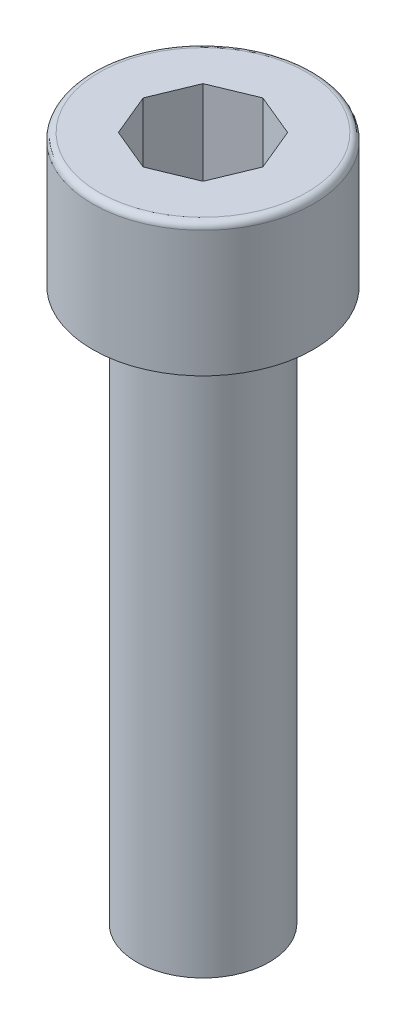
from build123d import *

# Parameters (mm, degrees)
SKETCH1_R           = 3
BOSS_EXTRUDE1_DEPTH = 25
SKETCH2_R           = 5
SKETCH2_R_2         = 3
BOSS_EXTRUDE2_DEPTH = 6
FILLET1_R           = 0.3
FILLET2_R           = 0.25


with BuildPart() as part:
    # Sketch1 → Boss-Extrude1 (new body)
    with BuildSketch(Plane(origin=(0, 0, 0), x_dir=(1, 0, 0), z_dir=(0, 1, 0))):
        Circle(SKETCH1_R)
    extrude(amount=BOSS_EXTRUDE1_DEPTH)

    # Sketch2 → Boss-Extrude2 (add)
    with BuildSketch(Plane(origin=(0, 25, 0), x_dir=(1, 0, 0), z_dir=(0, 1, 0))):
        Circle(SKETCH2_R)
        Circle(SKETCH2_R_2, mode=Mode.SUBTRACT)
        Circle(SKETCH2_R_2)
        Polygon((1.913417162, -1.913417162), (2.705980501, 0), (1.913417162, 1.913417162), (0, 2.705980501), (-1.913417162, 1.913417162), (-2.705980501, 0), (-1.913417162, -1.913417162), (0, -2.705980501), align=None, mode=Mode.SUBTRACT)
    extrude(amount=BOSS_EXTRUDE2_DEPTH)

    # Fillet1
    fillet1_edges = [part.edges().sort_by_distance(p)[0] for p in [
        (-5, 31, 0),
    ]]
    fillet(fillet1_edges, radius=FILLET1_R)

    # Fillet2
    fillet2_edges = [part.edges().sort_by_distance(p)[0] for p in [
        (-3, 25, 0),
    ]]
    fillet(fillet2_edges, radius=FILLET2_R)


solid = part.part
